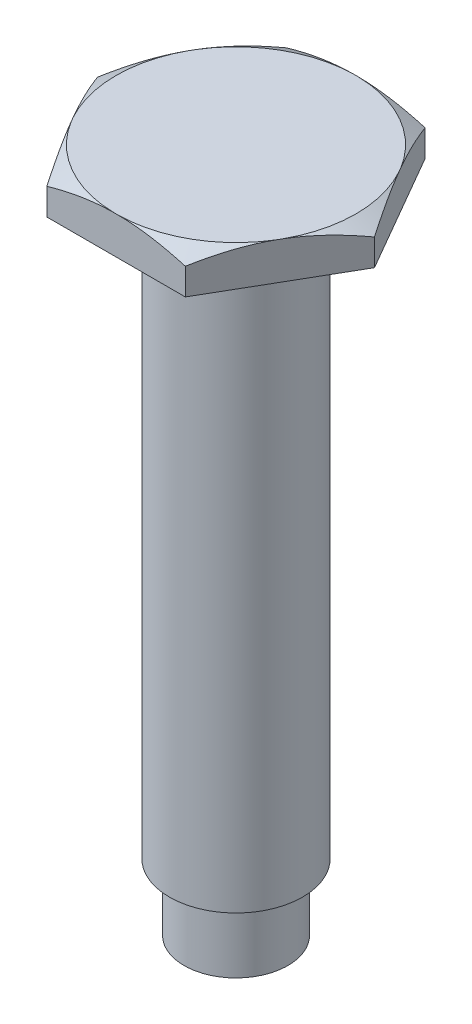
from build123d import *

# Parameters (mm, degrees)
BOSS_EXTRUDE1_DEPTH = 1.4
SKETCH2_OUTSIDE_W   = 18.618
SKETCH2_OUTSIDE_H   = 17.226
SKETCH2_OUTSIDE_R   = 4.5
CUT_EXTRUDE1_DEPTH  = 1
CUT_EXTRUDE1_TAPER  = 60
SKETCH3_R           = 2.5
BOSS_EXTRUDE2_DEPTH = 24.3
SKETCH4_OUTSIDE_W   = 18.218
SKETCH4_OUTSIDE_H   = 16.826
SKETCH4_OUTSIDE_R   = 1.95
CUT_EXTRUDE2_DEPTH  = 2.5


with BuildPart() as part:
    # Sketch1 → Boss-Extrude1 (new body)
    with BuildSketch(Plane(origin=(0, 0, 0), x_dir=(1, 0, 0), z_dir=(0, 1, 0))):
        Polygon((5.195, 0), (2.5975, 4.499001973), (-2.5975, 4.499001973), (-5.195, 0), (-2.5975, -4.499001973), (2.5975, -4.499001973), align=None)
    extrude(amount=BOSS_EXTRUDE1_DEPTH)

    # Sketch2 outside → Cut-Extrude1 (cut)
    with BuildSketch(Plane(origin=(0, 1.4, 0), x_dir=(1, 0, 0), z_dir=(0, 1, 0))):
        Rectangle(SKETCH2_OUTSIDE_W, SKETCH2_OUTSIDE_H)
        Circle(SKETCH2_OUTSIDE_R, mode=Mode.SUBTRACT)
    extrude(amount=-CUT_EXTRUDE1_DEPTH, taper=CUT_EXTRUDE1_TAPER, mode=Mode.SUBTRACT)

    # Sketch3 → Boss-Extrude2 (add)
    with BuildSketch(Plane.XZ):
        Circle(SKETCH3_R)
    extrude(amount=BOSS_EXTRUDE2_DEPTH)

    # Sketch4 outside → Cut-Extrude2 (cut)
    with BuildSketch(Plane.XZ.offset(24.3)):
        Rectangle(SKETCH4_OUTSIDE_W, SKETCH4_OUTSIDE_H)
        Circle(SKETCH4_OUTSIDE_R, mode=Mode.SUBTRACT)
    extrude(amount=-CUT_EXTRUDE2_DEPTH, mode=Mode.SUBTRACT)


solid = part.part
